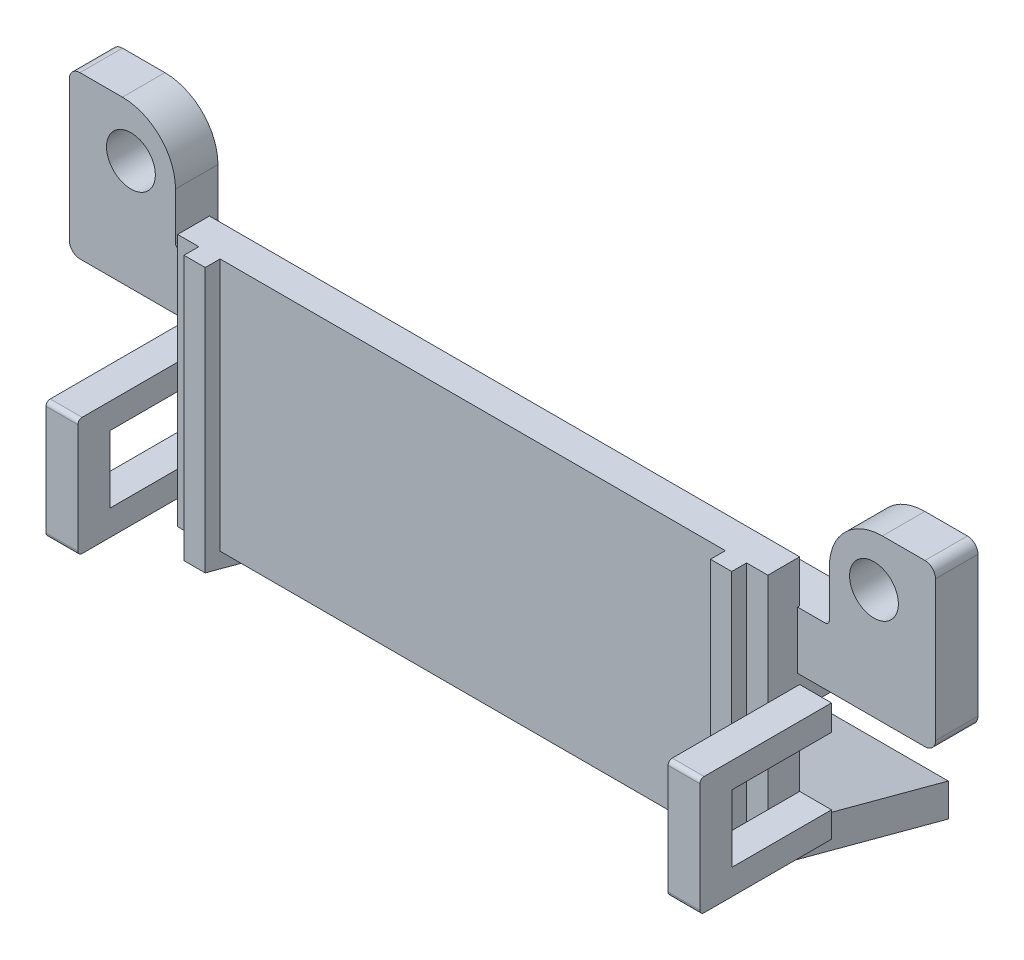
from build123d import *

# Parameters (mm, degrees)
SKETCH_1_W          = 27.8
SKETCH_1_H          = 8
EXTRUDE_1_DEPTH     = 7.8
EXTRUDE_2_DEPTH     = 27.8
SKETCH_4_R          = 1.15
EXTRUDE_3_DEPTH     = 2
CUT_EXTRUDE_4_DEPTH = 24.8
SKETCH_15_W         = 27.8
SKETCH_15_H         = 4.251772847
EXTRUDE_4_DEPTH     = 1.9
FILLET_1_R          = 8
FILLET_2_R          = 6.5
EXTRUDE_5_DEPTH     = 27.8
CUT_EXTRUDE_6_DEPTH = 24.8
SKETCH_19_OUTSIDE_W = 26.556
SKETCH_19_OUTSIDE_H = 34.032
CUT_EXTRUDE_7_DEPTH = 40.8
SKETCH_20_W         = 1.5
SKETCH_20_H         = 5.56
EXTRUDE_6_DEPTH     = 6.2
SKETCH_21_W         = 1.5
SKETCH_21_H         = 3.16
CUT_EXTRUDE_8_DEPTH = 4.68
EXTRUDE_7_DEPTH     = 1
FILLET_3_R          = 0.2


with BuildPart() as part:
    # 草图1 → 凸台-拉伸1 (new body)
    with BuildSketch(Plane.XY):
        with Locations((13.9, -4)):
            Rectangle(SKETCH_1_W, SKETCH_1_H)
    extrude(amount=EXTRUDE_1_DEPTH)

    # 草图2 → 凸台-拉伸2 (add)
    with BuildSketch(Plane.ZY):
        Polygon((5.795554958, -15.947085729), (0, -17.5), (0, -8), (7.8, -8), align=None)
    extrude(amount=-EXTRUDE_2_DEPTH)

    # 草图4 → 凸台-拉伸3 (add)
    with BuildSketch(Plane(origin=(0, 0, -1.9), x_dir=(-1, 0, 0), z_dir=(0, 0, -1))):
        with BuildLine():
            Line((0, -2), (0, -4.7))
            Line((0, -4.7), (6, -4.7))
            ThreePointArc((6, -4.7), (6.353553391, -4.553553391), (6.5, -4.2))
            Line((6.5, -4.2), (6.5, -2))
            Line((6.5, -2), (6.5, 2.4))
            ThreePointArc((6.5, 2.4), (6.353553391, 2.753553391), (6, 2.9))
            Line((6, 2.9), (4, 2.9))
            ThreePointArc((4, 2.9), (2.232233047, 2.167766953), (1.5, 0.4))
            Line((1.5, 0.4), (1.5, -1.8))
            ThreePointArc((1.5, -1.8), (1.441421356, -1.941421356), (1.3, -2))
            Line((1.3, -2), (0, -2))
        make_face()
        with Locations((3.6, 0.5)):
            Circle(SKETCH_4_R, mode=Mode.SUBTRACT)
    extrude_3 = extrude(amount=-EXTRUDE_3_DEPTH)

    # 镜向1: 凸台-拉伸3 across plane
    add(extrude_3.mirror(Plane.ZY.offset(-13.9)))

    # 草图13 → 切除-拉伸4 (cut)
    with BuildSketch(Plane.ZY.offset(-1.5)):
        Polygon((1.5, 0), (1.5, -11.921695309), (0, -12.323619098), (0, -15.947085729), (4.556522218, -14.726169281), (6.3, -7.813748582), (6.3, 0), align=None)
    extrude(amount=-CUT_EXTRUDE_4_DEPTH, mode=Mode.SUBTRACT)

    # 草图15 → 凸台-拉伸4 (add)
    with BuildSketch(Plane(origin=(0, 0, 0), x_dir=(-1, 0, 0), z_dir=(0, 0, -1))):
        with Locations((-13.9, -4.125886424)):
            Rectangle(SKETCH_15_W, SKETCH_15_H)
    extrude(amount=EXTRUDE_4_DEPTH)

    # 圆角1
    fillet_1_edges = [part.edges().sort_by_distance(p)[0] for p in [
        (13.9, -14.726169281, 4.556522218),
    ]]
    fillet(fillet_1_edges, radius=FILLET_1_R)

    # 圆角2
    fillet_2_edges = [part.edges().sort_by_distance(p)[0] for p in [
        (13.9, -15.947085729, 5.795554958),
    ]]
    fillet(fillet_2_edges, radius=FILLET_2_R)

    # 草图17 → 凸台-拉伸5 (add)
    with BuildSketch(Plane(origin=(27.8, 0, 0), x_dir=(0, 0, -1), z_dir=(1, 0, 0))):
        Polygon((0, -17.5), (7, -19.375644347), (7, -12.646349174), (0, -10.770704827), align=None)
    extrude(amount=-EXTRUDE_5_DEPTH)

    # 草图18 → 切除-拉伸6 (cut)
    with BuildSketch(Plane.ZY.offset(-26.3)):
        Polygon((0, -12.323619098), (0, -15.947085729), (-7, -17.822730076), (-7, -14.199263445), align=None)
    extrude(amount=CUT_EXTRUDE_6_DEPTH, mode=Mode.SUBTRACT)

    # 草图19 outside → 切除-拉伸7 (cut)
    with BuildSketch(Plane(origin=(34.3, 0, 0), x_dir=(0, 0, -1), z_dir=(1, 0, 0))):
        with Locations((-0.4, -8.238)):
            Rectangle(SKETCH_19_OUTSIDE_W, SKETCH_19_OUTSIDE_H)
        Polygon((7, 2.9), (7, -14.199263445), (-1.5, -11.921695309), (-1.5, 2.9), align=None, mode=Mode.SUBTRACT)
    extrude(amount=-CUT_EXTRUDE_7_DEPTH, mode=Mode.SUBTRACT)

    # 草图20 → 凸台-拉伸6 (add)
    with BuildSketch(Plane(origin=(0, -7.983041289, 0), x_dir=(1, 0, 0), z_dir=(0, 0, -1))):
        with Locations((-0.75, 0.007663538)):
            Rectangle(SKETCH_20_W, SKETCH_20_H)
    extrude_6 = extrude(amount=-EXTRUDE_6_DEPTH)

    # 草图21 → 切除-拉伸8 (cut)
    with BuildSketch(Plane(origin=(0, -7.983041289, 0), x_dir=(1, 0, 0), z_dir=(0, 0, -1))):
        with Locations((-0.75, 0.007663538)):
            Rectangle(SKETCH_21_W, SKETCH_21_H)
    cut_extrude_8 = extrude(amount=-CUT_EXTRUDE_8_DEPTH, mode=Mode.SUBTRACT)

    # 镜向2: 凸台-拉伸6, 切除-拉伸8 across plane
    add(extrude_6.mirror(Plane.ZY.offset(-13.9)))
    add(cut_extrude_8.mirror(Plane.ZY.offset(-13.9)), mode=Mode.SUBTRACT)

    # 草图23 → 凸台-拉伸7 (add)
    with BuildSketch(Plane.ZY.offset(-1)):
        Polygon((1.5, 0), (1.5, -11.921695309), (-7, -14.199263445), (-7, -14.923956771), (2.2, -12.458824201), (2.2, 0), align=None)
    extrude_7 = extrude(amount=-EXTRUDE_7_DEPTH)

    # 镜向3: 凸台-拉伸7 across plane
    add(extrude_7.mirror(Plane.ZY.offset(-13.9)))

    # 圆角3
    fillet_3_edges = [part.edges().sort_by_distance(p)[0] for p in [
        (-0.75, -5.210704827, 6.2),
        (-0.75, -10.770704827, 6.2),
        (28.55, -10.770704827, 6.2),
        (28.55, -5.210704827, 6.2),
    ]]
    fillet(fillet_3_edges, radius=FILLET_3_R)


solid = part.part
